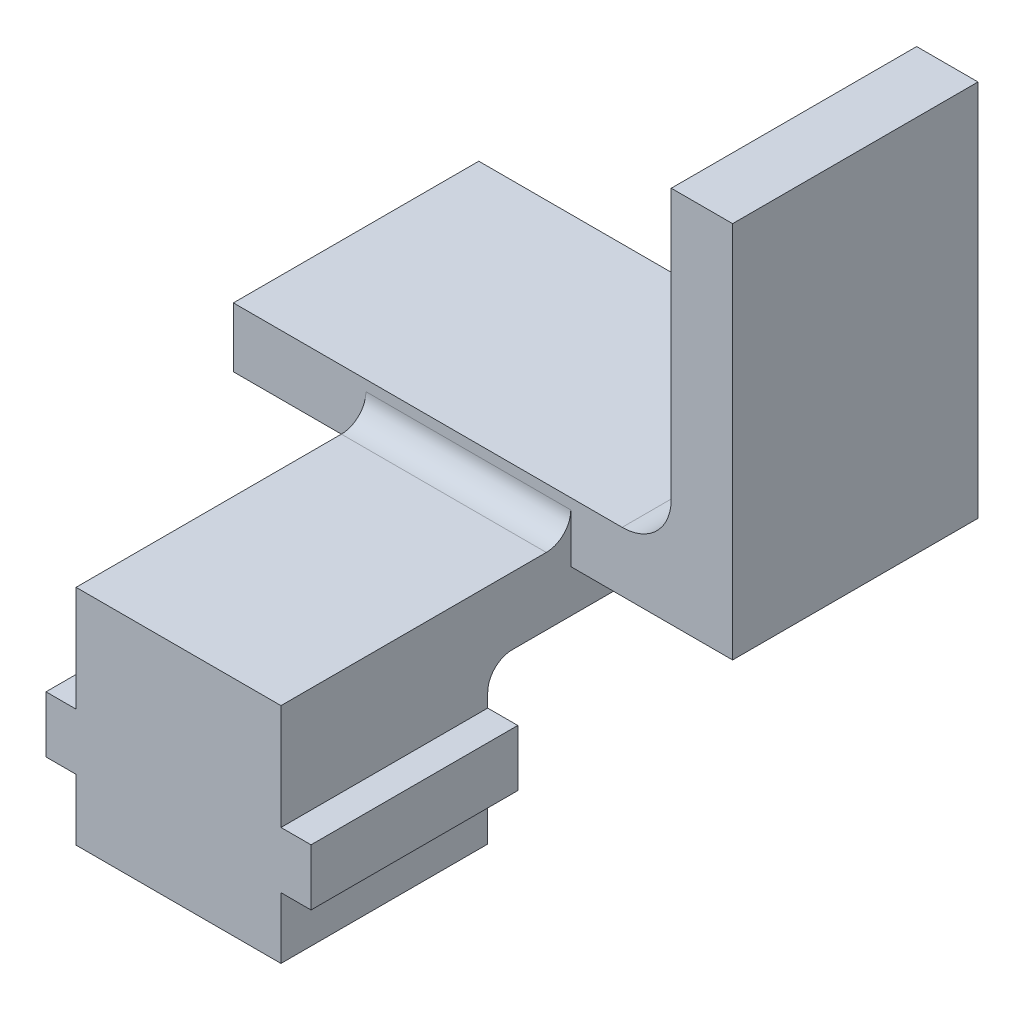
from build123d import *

# Parameters (mm, degrees)
BOSS_EXTRUDE1_DEPTH = 12.7
FILLET1_R           = 2.54
BOSS_EXTRUDE2_DEPTH = 15
SKETCH3_W           = 20.43801088
SKETCH3_H           = 11.408302333
CUT_EXTRUDE1_DEPTH  = 17
FILLET2_R           = 1.27


with BuildPart() as part:
    # Sketch1 → Boss-Extrude1 (new body)
    with BuildSketch(Plane.XY):
        Polygon((0, 0), (0, -4.191), (-1.55575, -4.191), (-1.55575, -7.112), (0, -7.112), (0, -10.287), (10.6045, -10.287), (10.6045, -7.112), (12.16025, -7.112), (12.16025, -4.191), (10.6045, -4.191), (10.6045, 0), (18.97725, 0), (18.97725, 19.558), (15.80225, 19.558), (15.80225, 3.089), (-6.858, 3.089), (-6.858, 0), align=None)
    extrude(amount=BOSS_EXTRUDE1_DEPTH)

    # Fillet1
    fillet1_edges = [part.edges().sort_by_distance(p)[0] for p in [
        (15.80225, 3.089, 6.35),
    ]]
    fillet(fillet1_edges, radius=FILLET1_R)

    # Sketch2 → Boss-Extrude2 (add)
    with BuildSketch(Plane.XY.offset(12.7)):
        Polygon((0, 0), (0, 1.27), (10.6045, 1.27), (10.6045, 0), (10.6045, -4.191), (12.16025, -4.191), (12.16025, -7.112), (10.6045, -7.112), (10.6045, -10.287), (0, -10.287), (0, -7.112), (-1.55575, -7.112), (-1.55575, -4.191), (0, -4.191), align=None)
    extrude(amount=BOSS_EXTRUDE2_DEPTH)

    # Sketch3 → Cut-Extrude1 (cut)
    with BuildSketch(Plane(origin=(0, 0, 0), x_dir=(-1, 0, 0), z_dir=(0, 0, -1))):
        with Locations((-3.189611216, -7.915151167)):
            Rectangle(SKETCH3_W, SKETCH3_H)
    extrude(amount=-CUT_EXTRUDE1_DEPTH, mode=Mode.SUBTRACT)

    # Fillet2
    fillet2_edges = [part.edges().sort_by_distance(p)[0] for p in [
        (5.30225, -2.211, 17),
        (5.30225, 1.27, 12.7),
    ]]
    fillet(fillet2_edges, radius=FILLET2_R)


solid = part.part
